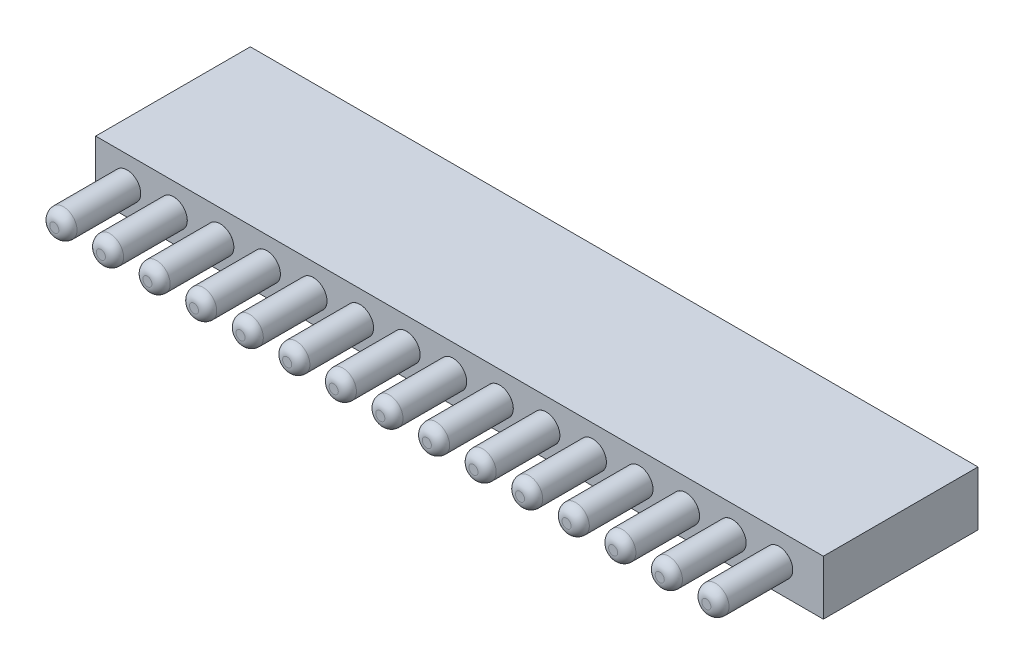
from build123d import *

# Parameters (mm, degrees)
SKETCH1_R              = 0.75
BOSS_EXTRUDE1_DEPTH    = 4
BOSS_EXTRUDE1_2_DEPTH  = 4
BOSS_EXTRUDE1_3_DEPTH  = 4
BOSS_EXTRUDE1_4_DEPTH  = 4
BOSS_EXTRUDE1_5_DEPTH  = 4
BOSS_EXTRUDE1_6_DEPTH  = 4
BOSS_EXTRUDE1_7_DEPTH  = 4
BOSS_EXTRUDE1_8_DEPTH  = 4
BOSS_EXTRUDE1_9_DEPTH  = 4
BOSS_EXTRUDE1_10_DEPTH = 4
BOSS_EXTRUDE1_11_DEPTH = 4
BOSS_EXTRUDE1_12_DEPTH = 4
BOSS_EXTRUDE1_13_DEPTH = 4
BOSS_EXTRUDE1_14_DEPTH = 4
BOSS_EXTRUDE1_15_DEPTH = 4
FILLET1_R              = 0.5
SKETCH2_W              = 40
SKETCH2_H              = 3
SKETCH2_R              = 0.75
BOSS_EXTRUDE2_DEPTH    = 8.5
FILLET2_R              = 0.5
FILLET3_R              = 0.5
FILLET4_R              = 0.5
FILLET5_R              = 0.5
FILLET6_R              = 0.5
FILLET7_R              = 0.5
FILLET8_R              = 0.5
FILLET9_R              = 0.5
FILLET10_R             = 0.5
FILLET11_R             = 0.5
FILLET12_R             = 0.5
FILLET13_R             = 0.5
FILLET14_R             = 0.5
FILLET15_R             = 0.5


with BuildPart() as part:
    # Sketch1 → Boss-Extrude1 (new body)
    with BuildSketch(Plane.XY):
        Circle(SKETCH1_R)
    extrude(amount=BOSS_EXTRUDE1_DEPTH)

    # Fillet1
    fillet1_edges = [part.edges().sort_by_distance(p)[0] for p in [
        (-0.75, 0, 4),
    ]]
    fillet(fillet1_edges, radius=FILLET1_R)


with BuildPart() as body_2:
    # Sketch1 → Boss-Extrude1 2 (new body)
    with BuildSketch(Plane.XY):
        with Locations((2.56, 0)):
            Circle(SKETCH1_R)
    extrude(amount=BOSS_EXTRUDE1_2_DEPTH)

    # Fillet2
    fillet2_edges = [body_2.edges().sort_by_distance(p)[0] for p in [
        (1.81, 0, 4),
    ]]
    fillet(fillet2_edges, radius=FILLET2_R)


with BuildPart() as body_3:
    # Sketch1 → Boss-Extrude1 3 (new body)
    with BuildSketch(Plane.XY):
        with Locations((5.12, 0)):
            Circle(SKETCH1_R)
    extrude(amount=BOSS_EXTRUDE1_3_DEPTH)

    # Fillet3
    fillet3_edges = [body_3.edges().sort_by_distance(p)[0] for p in [
        (4.37, 0, 4),
    ]]
    fillet(fillet3_edges, radius=FILLET3_R)


with BuildPart() as body_4:
    # Sketch1 → Boss-Extrude1 4 (new body)
    with BuildSketch(Plane.XY):
        with Locations((7.68, 0)):
            Circle(SKETCH1_R)
    extrude(amount=BOSS_EXTRUDE1_4_DEPTH)

    # Fillet4
    fillet4_edges = [body_4.edges().sort_by_distance(p)[0] for p in [
        (6.93, 0, 4),
    ]]
    fillet(fillet4_edges, radius=FILLET4_R)


with BuildPart() as body_5:
    # Sketch1 → Boss-Extrude1 5 (new body)
    with BuildSketch(Plane.XY):
        with Locations((10.24, 0)):
            Circle(SKETCH1_R)
    extrude(amount=BOSS_EXTRUDE1_5_DEPTH)

    # Fillet5
    fillet5_edges = [body_5.edges().sort_by_distance(p)[0] for p in [
        (9.49, 0, 4),
    ]]
    fillet(fillet5_edges, radius=FILLET5_R)


with BuildPart() as body_6:
    # Sketch1 → Boss-Extrude1 6 (new body)
    with BuildSketch(Plane.XY):
        with Locations((12.8, 0)):
            Circle(SKETCH1_R)
    extrude(amount=BOSS_EXTRUDE1_6_DEPTH)

    # Fillet6
    fillet6_edges = [body_6.edges().sort_by_distance(p)[0] for p in [
        (12.05, 0, 4),
    ]]
    fillet(fillet6_edges, radius=FILLET6_R)


with BuildPart() as body_7:
    # Sketch1 → Boss-Extrude1 7 (new body)
    with BuildSketch(Plane.XY):
        with Locations((15.36, 0)):
            Circle(SKETCH1_R)
    extrude(amount=BOSS_EXTRUDE1_7_DEPTH)

    # Fillet7
    fillet7_edges = [body_7.edges().sort_by_distance(p)[0] for p in [
        (14.61, 0, 4),
    ]]
    fillet(fillet7_edges, radius=FILLET7_R)


with BuildPart() as body_8:
    # Sketch1 → Boss-Extrude1 8 (new body)
    with BuildSketch(Plane.XY):
        with Locations((17.92, 0)):
            Circle(SKETCH1_R)
    extrude(amount=BOSS_EXTRUDE1_8_DEPTH)

    # Fillet8
    fillet8_edges = [body_8.edges().sort_by_distance(p)[0] for p in [
        (17.17, 0, 4),
    ]]
    fillet(fillet8_edges, radius=FILLET8_R)


with BuildPart() as body_9:
    # Sketch1 → Boss-Extrude1 9 (new body)
    with BuildSketch(Plane.XY):
        with Locations((20.48, 0)):
            Circle(SKETCH1_R)
    extrude(amount=BOSS_EXTRUDE1_9_DEPTH)

    # Fillet9
    fillet9_edges = [body_9.edges().sort_by_distance(p)[0] for p in [
        (19.73, 0, 4),
    ]]
    fillet(fillet9_edges, radius=FILLET9_R)


with BuildPart() as body_10:
    # Sketch1 → Boss-Extrude1 10 (new body)
    with BuildSketch(Plane.XY):
        with Locations((23.04, 0)):
            Circle(SKETCH1_R)
    extrude(amount=BOSS_EXTRUDE1_10_DEPTH)

    # Fillet10
    fillet10_edges = [body_10.edges().sort_by_distance(p)[0] for p in [
        (22.29, 0, 4),
    ]]
    fillet(fillet10_edges, radius=FILLET10_R)


with BuildPart() as body_11:
    # Sketch1 → Boss-Extrude1 11 (new body)
    with BuildSketch(Plane.XY):
        with Locations((25.6, 0)):
            Circle(SKETCH1_R)
    extrude(amount=BOSS_EXTRUDE1_11_DEPTH)

    # Fillet11
    fillet11_edges = [body_11.edges().sort_by_distance(p)[0] for p in [
        (24.85, 0, 4),
    ]]
    fillet(fillet11_edges, radius=FILLET11_R)


with BuildPart() as body_12:
    # Sketch1 → Boss-Extrude1 12 (new body)
    with BuildSketch(Plane.XY):
        with Locations((28.16, 0)):
            Circle(SKETCH1_R)
    extrude(amount=BOSS_EXTRUDE1_12_DEPTH)

    # Fillet12
    fillet12_edges = [body_12.edges().sort_by_distance(p)[0] for p in [
        (27.41, 0, 4),
    ]]
    fillet(fillet12_edges, radius=FILLET12_R)


with BuildPart() as body_13:
    # Sketch1 → Boss-Extrude1 13 (new body)
    with BuildSketch(Plane.XY):
        with Locations((30.72, 0)):
            Circle(SKETCH1_R)
    extrude(amount=BOSS_EXTRUDE1_13_DEPTH)

    # Fillet13
    fillet13_edges = [body_13.edges().sort_by_distance(p)[0] for p in [
        (29.97, 0, 4),
    ]]
    fillet(fillet13_edges, radius=FILLET13_R)


with BuildPart() as body_14:
    # Sketch1 → Boss-Extrude1 14 (new body)
    with BuildSketch(Plane.XY):
        with Locations((33.28, 0)):
            Circle(SKETCH1_R)
    extrude(amount=BOSS_EXTRUDE1_14_DEPTH)

    # Fillet14
    fillet14_edges = [body_14.edges().sort_by_distance(p)[0] for p in [
        (32.53, 0, 4),
    ]]
    fillet(fillet14_edges, radius=FILLET14_R)


with BuildPart() as body_15:
    # Sketch1 → Boss-Extrude1 15 (new body)
    with BuildSketch(Plane.XY):
        with Locations((35.84, 0)):
            Circle(SKETCH1_R)
    extrude(amount=BOSS_EXTRUDE1_15_DEPTH)

    # Fillet15
    fillet15_edges = [body_15.edges().sort_by_distance(p)[0] for p in [
        (35.09, 0, 4),
    ]]
    fillet(fillet15_edges, radius=FILLET15_R)


with BuildPart() as body_16:
    # Sketch2 → Boss-Extrude2 (new body)
    with BuildSketch(Plane(origin=(0, 0, 0), x_dir=(-1, 0, 0), z_dir=(0, 0, -1))):
        with Locations((-18.274877859, 0)):
            Rectangle(SKETCH2_W, SKETCH2_H)
        with Locations((-30.72, 0)):
            Circle(SKETCH2_R, mode=Mode.SUBTRACT)
        with Locations((-28.16, 0)):
            Circle(SKETCH2_R, mode=Mode.SUBTRACT)
        with Locations((-25.6, 0)):
            Circle(SKETCH2_R, mode=Mode.SUBTRACT)
        with Locations((-23.04, 0)):
            Circle(SKETCH2_R, mode=Mode.SUBTRACT)
        with Locations((-20.48, 0)):
            Circle(SKETCH2_R, mode=Mode.SUBTRACT)
        with Locations((-10.24, 0)):
            Circle(SKETCH2_R, mode=Mode.SUBTRACT)
        with Locations((-35.84, 0)):
            Circle(SKETCH2_R, mode=Mode.SUBTRACT)
        with Locations((-33.28, 0)):
            Circle(SKETCH2_R, mode=Mode.SUBTRACT)
        with Locations((-17.92, 0)):
            Circle(SKETCH2_R, mode=Mode.SUBTRACT)
        with Locations((-15.36, 0)):
            Circle(SKETCH2_R, mode=Mode.SUBTRACT)
        with Locations((-12.8, 0)):
            Circle(SKETCH2_R, mode=Mode.SUBTRACT)
        with Locations((-7.68, 0)):
            Circle(SKETCH2_R, mode=Mode.SUBTRACT)
        with Locations((-5.12, 0)):
            Circle(SKETCH2_R, mode=Mode.SUBTRACT)
        with Locations((-2.56, 0)):
            Circle(SKETCH2_R, mode=Mode.SUBTRACT)
        Circle(SKETCH2_R, mode=Mode.SUBTRACT)
    extrude(amount=BOSS_EXTRUDE2_DEPTH)


solid = Compound([part.part, body_2.part, body_3.part, body_4.part, body_5.part, body_6.part, body_7.part, body_8.part, body_9.part, body_10.part, body_11.part, body_12.part, body_13.part, body_14.part, body_15.part, body_16.part])
